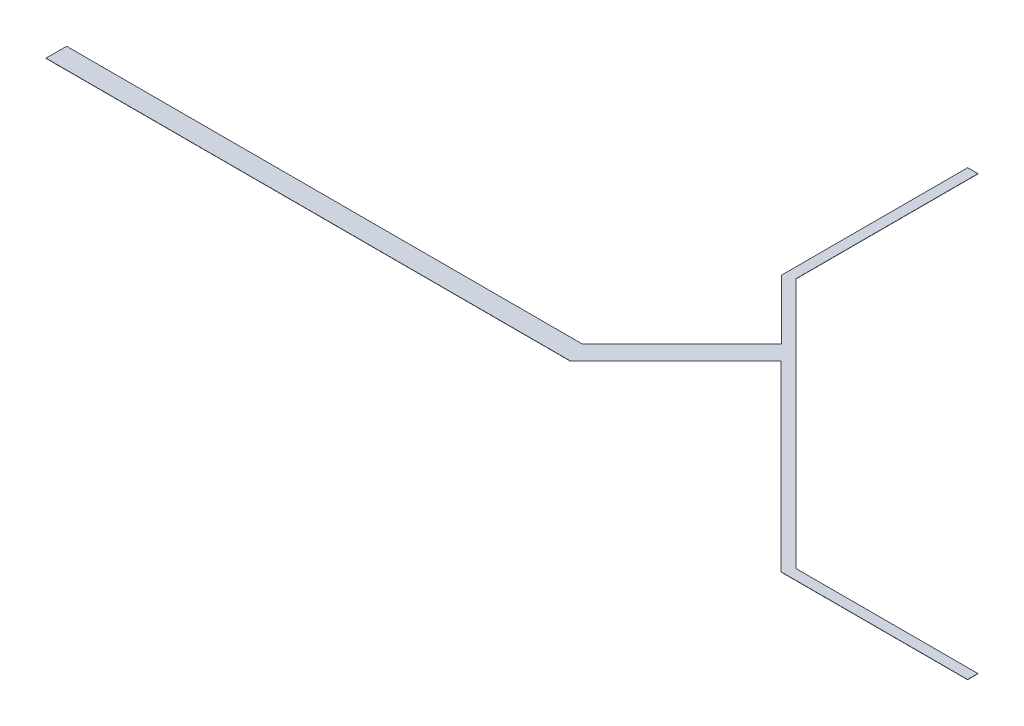
from build123d import *

# Parameters (mm, degrees)
BOSS_EXTRUDE1_DEPTH = 0.02
SCALE1_SCALE        = 0.75


with BuildPart() as part:
    # Sketch1 → Boss-Extrude1 (new body)
    with BuildSketch(Plane(origin=(0, 0, 0), x_dir=(1, 0, 0), z_dir=(0, 1, 0))):
        Polygon((0, 0), (0, 2), (50, 2), (59.652007563, 11.652007563), (53.889087297, 17.41492783), (53.889087297, 35.49492783), (54.889087297, 35.49492783), (54.889087297, 17.83492783), (79.209002128, -6.495331881), (96.869002128, -6.495331881), (96.869002128, -7.495331881), (78.789002128, -7.495331881), (61.061835124, 10.231835124), (50.83, 0), align=None)
    extrude(amount=BOSS_EXTRUDE1_DEPTH)


with BuildPart() as part_1:
    # Scale1: scaled about (44.956647526, 0.01, -4.024879093)
    add(part.part.scale(SCALE1_SCALE).moved(Location((11.239161881, 0.0025, -1.006219773))))


solid = part_1.part
